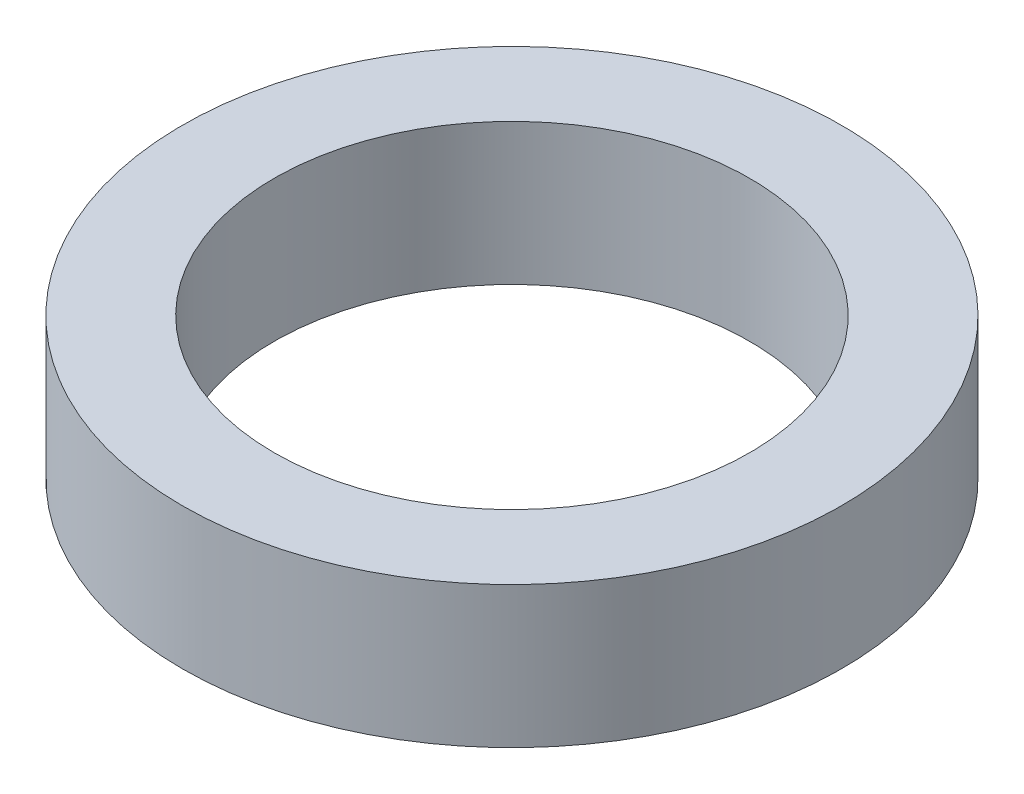
from build123d import *

# Parameters (mm, degrees)
SKETCH1_R           = 3.5
SKETCH1_R_2         = 2.525
BOSS_EXTRUDE1_DEPTH = 1.5


with BuildPart() as part:
    # Sketch1 → Boss-Extrude1 (new body)
    with BuildSketch(Plane(origin=(0, 0, 0), x_dir=(1, 0, 0), z_dir=(0, 1, 0))):
        Circle(SKETCH1_R)
        Circle(SKETCH1_R_2, mode=Mode.SUBTRACT)
    extrude(amount=BOSS_EXTRUDE1_DEPTH)


solid = part.part
